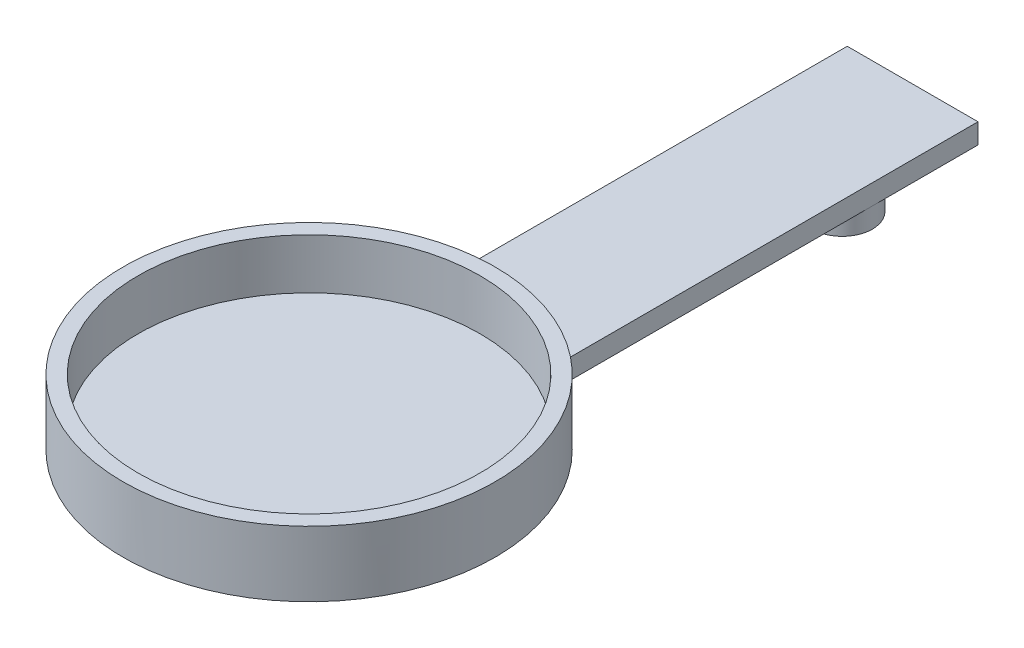
from build123d import *

# Parameters (mm, degrees)
SKETCH1_R                = 18.5
BOSS_EXTRUDE1_DEPTH      = 1.5
SKETCH2_R                = 18.5
SKETCH2_R_2              = 17
BOSS_EXTRUDE2_DEPTH      = 5
SKETCH3_W                = 13
SKETCH3_H                = 71.108724116
BOSS_EXTRUDE3_DEPTH      = 0.5
BOSS_EXTRUDE3_DEPTH_BACK = 1.5
SKETCH4_R                = 3
BOSS_EXTRUDE4_DEPTH      = 2
BOSS_EXTRUDE4_DEPTH_BACK = 0.5
CUT_EXTRUDE1_DEPTH       = 2
SKETCH7_R                = 1.4
CUT_EXTRUDE2_DEPTH       = 3


with BuildPart() as part:
    # Sketch1 → Boss-Extrude1 (new body)
    with BuildSketch(Plane(origin=(0, 0, 0), x_dir=(1, 0, 0), z_dir=(0, 1, 0))):
        Circle(SKETCH1_R)
    extrude(amount=BOSS_EXTRUDE1_DEPTH)

    # Sketch2 → Boss-Extrude2 (add)
    with BuildSketch(Plane(origin=(0, 1.5, 0), x_dir=(1, 0, 0), z_dir=(0, 1, 0))):
        Circle(SKETCH2_R)
        Circle(SKETCH2_R_2, mode=Mode.SUBTRACT)
    extrude(amount=BOSS_EXTRUDE2_DEPTH)

    # Sketch3 → Boss-Extrude3 (add, two sides)
    with BuildSketch(Plane(origin=(0, 0, 0), x_dir=(-1, 0, 0), z_dir=(0, -1, 0))) as boss_extrude3_sk:
        with Locations((0, 24.445637942)):
            Rectangle(SKETCH3_W, SKETCH3_H)
    extrude(amount=BOSS_EXTRUDE3_DEPTH)
    extrude(boss_extrude3_sk.sketch, amount=-BOSS_EXTRUDE3_DEPTH_BACK)

    # Sketch4 → Boss-Extrude4 (add, two sides)
    with BuildSketch(Plane(origin=(0, -0.5, 0), x_dir=(-1, 0, 0), z_dir=(0, -1, 0))) as boss_extrude4_sk:
        with Locations((3.5, -9.108724116)):
            Circle(SKETCH4_R)
        with Locations((-3.5, 49.5)):
            Circle(SKETCH4_R)
        with Locations((-3.5, -9.108724116)):
            Circle(SKETCH4_R)
    extrude(amount=BOSS_EXTRUDE4_DEPTH)
    extrude(boss_extrude4_sk.sketch, amount=-BOSS_EXTRUDE4_DEPTH_BACK)

    # Sketch6 → Cut-Extrude1 (cut)
    with BuildSketch(Plane(origin=(0, -2.5, 0), x_dir=(-1, 0, 0), z_dir=(0, -1, 0))):
        with BuildLine():
            Line((-3.5, 51.5), (-3.5, 52.5))
            ThreePointArc((-3.5, 52.5), (-0.5, 49.5), (-3.5, 46.5))
            Line((-3.5, 46.5), (-3.5, 47.5))
            ThreePointArc((-3.5, 47.5), (-1.5, 49.5), (-3.5, 51.5))
        make_face()
    extrude(amount=-CUT_EXTRUDE1_DEPTH, mode=Mode.SUBTRACT)

    # Sketch7 → Cut-Extrude2 (cut)
    with BuildSketch(Plane(origin=(0, -2.5, 0), x_dir=(-1, 0, 0), z_dir=(0, -1, 0))):
        with Locations((-3.5, 49.5)):
            Circle(SKETCH7_R)
        with Locations((3.5, -9.108724116)):
            Circle(SKETCH7_R)
    extrude(amount=-CUT_EXTRUDE2_DEPTH, mode=Mode.SUBTRACT)


solid = part.part
